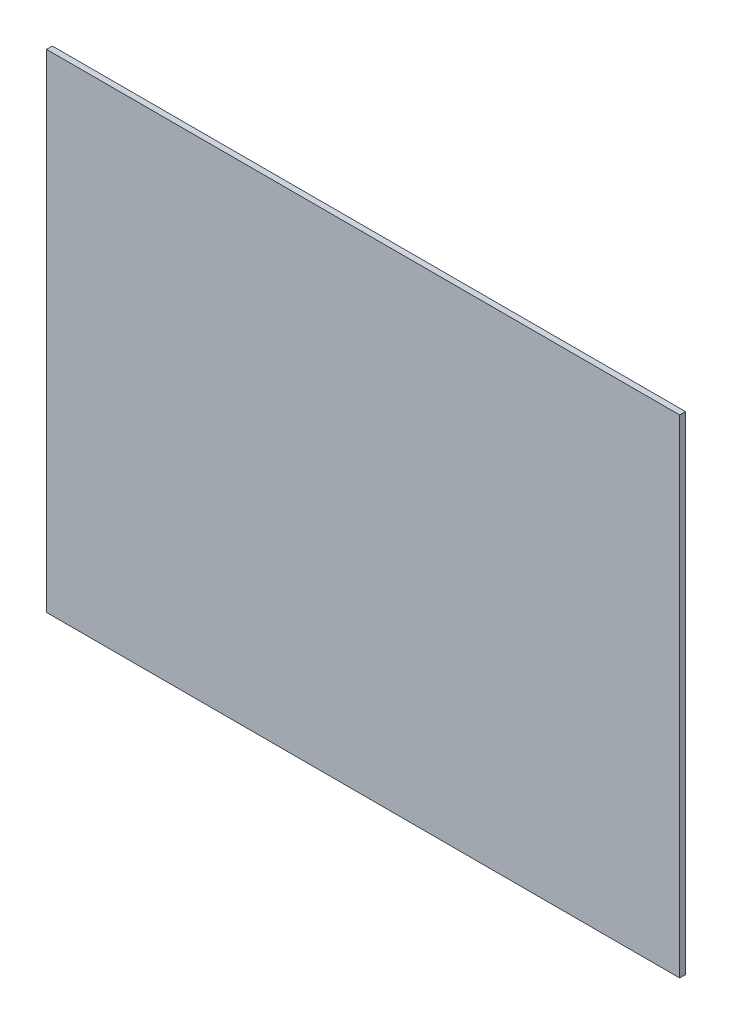
from build123d import *

# Parameters (mm, degrees)
IZIM1_W                     = 326.2
IZIM1_H                     = 251.2
Y_KSEKLIK_EKSTR_ZYON1_DEPTH = 3


with BuildPart() as part:
    # Çizim1 → Yükseklik-Ekstrüzyon1 (new body)
    with BuildSketch(Plane.XY):
        Rectangle(IZIM1_W, IZIM1_H)
    extrude(amount=-Y_KSEKLIK_EKSTR_ZYON1_DEPTH)


solid = part.part
